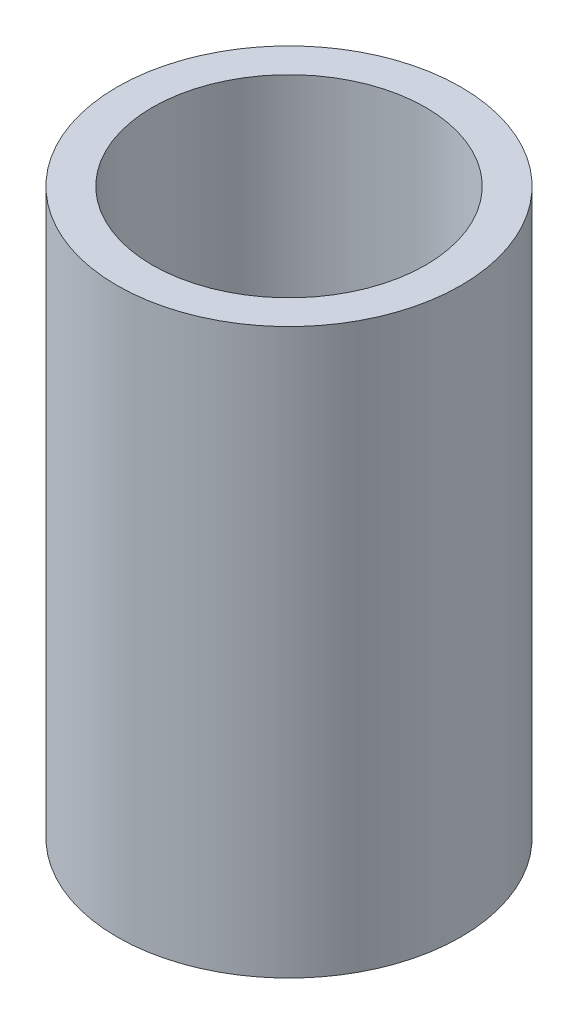
from build123d import *

# Parameters (mm, degrees)
SKETCH1_R           = 15.478125
SKETCH1_R_2         = 12.303125
BOSS_EXTRUDE1_DEPTH = 50.8


with BuildPart() as part:
    # Sketch1 → Boss-Extrude1 (new body)
    with BuildSketch(Plane(origin=(0, 0, 0), x_dir=(1, 0, 0), z_dir=(0, 1, 0))):
        Circle(SKETCH1_R)
        Circle(SKETCH1_R_2, mode=Mode.SUBTRACT)
    extrude(amount=BOSS_EXTRUDE1_DEPTH)


solid = part.part
